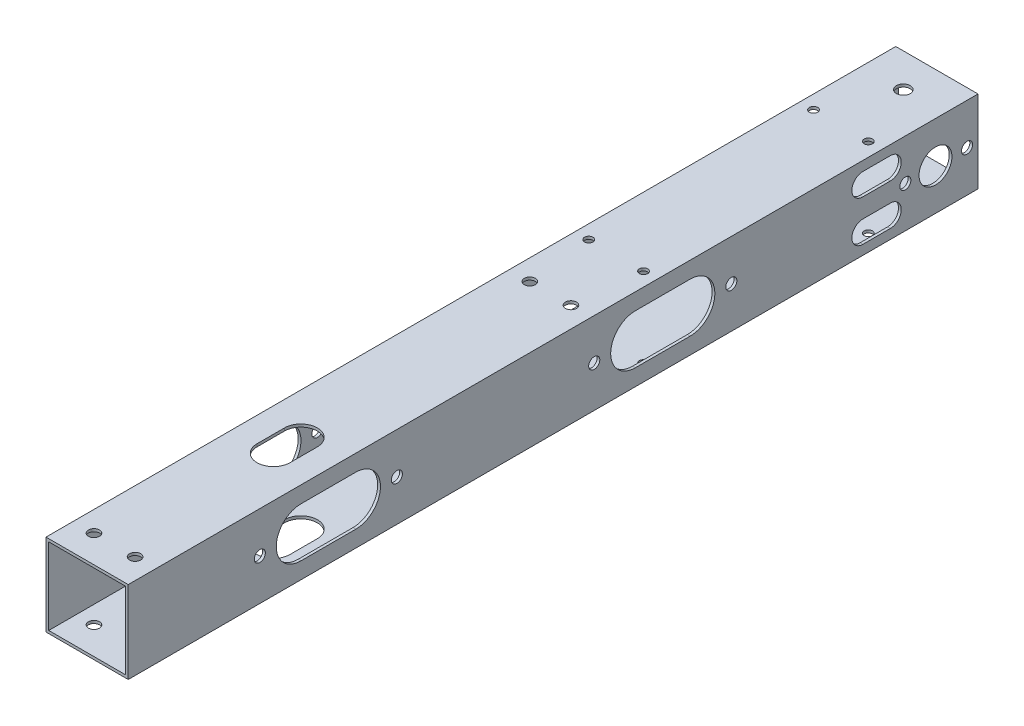
from build123d import *

# Parameters (mm, degrees)
SKETCH_1_W                = 30
SKETCH_1_H                = 30
EXTRUDE_1_DEPTH           = 155
SKETCH_2_W                = 28
SKETCH_2_H                = 28
CUT_EXTRUDE_1_DEPTH       = 156
CUT_EXTRUDE_1_DEPTH_BACK  = 156
SKETCH_3_R                = 2.025
CUT_EXTRUDE_2_DEPTH       = 31
SKETCH_4_R                = 2.025
CUT_EXTRUDE_3_DEPTH       = 1
CUT_EXTRUDE_3_DEPTH_BACK  = 31
SKETCH_5_R                = 2.025
CUT_EXTRUDE_4_DEPTH       = 1
CUT_EXTRUDE_4_DEPTH_BACK  = 31
SKETCH_6_W                = 20
SKETCH_6_H                = 20
CUT_EXTRUDE_5_DEPTH       = 3
FILLET_1_R                = 2
SKETCH_7_R                = 2.025
CUT_EXTRUDE_6_DEPTH       = 1
CUT_EXTRUDE_6_DEPTH_BACK  = 31
SKETCH_8_R                = 6
CUT_EXTRUDE_7_DEPTH       = 1
CUT_EXTRUDE_7_DEPTH_BACK  = 31
SKETCH_9_R                = 1.525
CUT_EXTRUDE_8_DEPTH       = 31
CUT_EXTRUDE_9_DEPTH       = 31
CUT_EXTRUDE_10_DEPTH      = 31
CUT_EXTRUDE_11_DEPTH      = 1
CUT_EXTRUDE_11_DEPTH_BACK = 31
CUT_EXTRUDE_START         = -29
CUT_EXTRUDE_12_DEPTH      = 30
CUT_EXTRUDE_12_DEPTH_BACK = 31
CUT_EXTRUDE_13_REACH      = 32
SKETCH_14_R               = 2.525


with BuildPart() as part:
    # 草图1 → 凸台-拉伸1 (new body, symmetric)
    with BuildSketch(Plane.XY):
        Rectangle(SKETCH_1_W, SKETCH_1_H)
    extrude(amount=EXTRUDE_1_DEPTH, both=True)

    # 草图2 → 切除-拉伸1 (cut, two sides)
    with BuildSketch(Plane.XY) as cut_extrude_1_sk:
        Rectangle(SKETCH_2_W, SKETCH_2_H)
    extrude(amount=CUT_EXTRUDE_1_DEPTH, mode=Mode.SUBTRACT)
    extrude(cut_extrude_1_sk.sketch, amount=-CUT_EXTRUDE_1_DEPTH_BACK, mode=Mode.SUBTRACT)

    # 草图3 → 切除-拉伸2 (cut, through all)
    with BuildSketch(Plane.ZY.offset(15)):
        with Locations((-151, 0)):
            Circle(SKETCH_3_R)
        with Locations((-128.5, 0)):
            Circle(SKETCH_3_R)
    extrude(amount=-CUT_EXTRUDE_2_DEPTH, mode=Mode.SUBTRACT)

    # 草图4 → 切除-拉伸3 (cut, two sides)
    with BuildSketch(Plane.ZY.offset(15)) as cut_extrude_3_sk:
        with Locations((-65, 0)):
            Circle(SKETCH_4_R)
        with Locations((-15, 0)):
            Circle(SKETCH_4_R)
        with Locations((107, 0)):
            Circle(SKETCH_4_R)
        with Locations((57, 0)):
            Circle(SKETCH_4_R)
    extrude(amount=CUT_EXTRUDE_3_DEPTH, mode=Mode.SUBTRACT)
    extrude(cut_extrude_3_sk.sketch, amount=-CUT_EXTRUDE_3_DEPTH_BACK, mode=Mode.SUBTRACT)

    # 草图5 → 切除-拉伸4 (cut, two sides)
    with BuildSketch(Plane.XZ.offset(15)) as cut_extrude_4_sk:
        with Locations((-7.5, 145)):
            Circle(SKETCH_5_R)
        with Locations((7.5, 145)):
            Circle(SKETCH_5_R)
    extrude(amount=CUT_EXTRUDE_4_DEPTH, mode=Mode.SUBTRACT)
    extrude(cut_extrude_4_sk.sketch, amount=-CUT_EXTRUDE_4_DEPTH_BACK, mode=Mode.SUBTRACT)

    # 草图6 → 切除-拉伸5 (cut)
    with BuildSketch(Plane.XZ.offset(15)):
        with Locations((0, -14)):
            Rectangle(SKETCH_6_W, SKETCH_6_H)
    extrude(amount=-CUT_EXTRUDE_5_DEPTH, mode=Mode.SUBTRACT)

    # 圆角1
    fillet_1_edges = [part.edges().sort_by_distance(p)[0] for p in [
        (-10, -14.5, -24),
        (-10, -14.5, -4),
        (10, -14.5, -4),
        (10, -14.5, -24),
    ]]
    fillet(fillet_1_edges, radius=FILLET_1_R)

    # 草图7 → 切除-拉伸6 (cut, two sides)
    with BuildSketch(Plane(origin=(0, 15, 0), x_dir=(1, 0, 0), z_dir=(0, 1, 0))) as cut_extrude_6_sk:
        with Locations((-7.5, 14)):
            Circle(SKETCH_7_R)
        with Locations((7.5, 14)):
            Circle(SKETCH_7_R)
    extrude(amount=CUT_EXTRUDE_6_DEPTH, mode=Mode.SUBTRACT)
    extrude(cut_extrude_6_sk.sketch, amount=-CUT_EXTRUDE_6_DEPTH_BACK, mode=Mode.SUBTRACT)

    # 草图8 → 切除-拉伸7 (cut, two sides)
    with BuildSketch(Plane.ZY.offset(15)) as cut_extrude_7_sk:
        with Locations((-139.5, 0)):
            Circle(SKETCH_8_R)
    extrude(amount=CUT_EXTRUDE_7_DEPTH, mode=Mode.SUBTRACT)
    extrude(cut_extrude_7_sk.sketch, amount=-CUT_EXTRUDE_7_DEPTH_BACK, mode=Mode.SUBTRACT)

    # 草图9 → 切除-拉伸8 (cut, through all)
    with BuildSketch(Plane(origin=(0, 15, 0), x_dir=(1, 0, 0), z_dir=(0, 1, 0))):
        with Locations((-10, 120)):
            Circle(SKETCH_9_R)
        with Locations((10, 120)):
            Circle(SKETCH_9_R)
        with Locations((-10, 38)):
            Circle(SKETCH_9_R)
        with Locations((10, 38)):
            Circle(SKETCH_9_R)
    extrude(amount=-CUT_EXTRUDE_8_DEPTH, mode=Mode.SUBTRACT)

    # 草图10 → 切除-拉伸9 (cut, through all)
    with BuildSketch(Plane.ZY.offset(15)):
        with BuildLine():
            Line((-50, 9), (-30, 9))
            ThreePointArc((-30, 9), (-21, 0), (-30, -9))
            Line((-30, -9), (-50, -9))
            ThreePointArc((-50, -9), (-59, 0), (-50, 9))
        make_face()
    extrude(amount=-CUT_EXTRUDE_9_DEPTH, mode=Mode.SUBTRACT)

    # 草图11 → 切除-拉伸10 (cut, through all)
    with BuildSketch(Plane.ZY.offset(15)):
        with BuildLine():
            Line((-123, 3.5), (-113, 3.5))
            ThreePointArc((-113, 3.5), (-109, 7.5), (-113, 11.5))
            Line((-113, 11.5), (-123, 11.5))
            ThreePointArc((-123, 11.5), (-127, 7.5), (-123, 3.5))
        make_face()
        with BuildLine():
            Line((-123, -11.5), (-113, -11.5))
            ThreePointArc((-113, -11.5), (-109, -7.5), (-113, -3.5))
            Line((-113, -3.5), (-123, -3.5))
            ThreePointArc((-123, -3.5), (-127, -7.5), (-123, -11.5))
        make_face()
    extrude(amount=-CUT_EXTRUDE_10_DEPTH, mode=Mode.SUBTRACT)

    # 草图12 → 切除-拉伸11 (cut, two sides)
    with BuildSketch(Plane.ZY.offset(15)) as cut_extrude_11_sk:
        with BuildLine():
            Line((72, 9), (92, 9))
            ThreePointArc((92, 9), (101, 0), (92, -9))
            Line((92, -9), (72, -9))
            ThreePointArc((72, -9), (63, 0), (72, 9))
        make_face()
    extrude(amount=CUT_EXTRUDE_11_DEPTH, mode=Mode.SUBTRACT)
    extrude(cut_extrude_11_sk.sketch, amount=-CUT_EXTRUDE_11_DEPTH_BACK, mode=Mode.SUBTRACT)

    # 草图13 → 切除-拉伸12 (cut, two sides)
    with BuildSketch(Plane(origin=(0, 15, 0), x_dir=(1, 0, 0), z_dir=(0, 1, 0)).offset(CUT_EXTRUDE_START)) as cut_extrude_12_sk:
        with BuildLine():
            Line((-6, -87), (-6, -77))
            ThreePointArc((-6, -77), (0, -71), (6, -77))
            Line((6, -77), (6, -87))
            ThreePointArc((6, -87), (0, -93), (-6, -87))
        make_face()
    extrude(amount=CUT_EXTRUDE_12_DEPTH, mode=Mode.SUBTRACT)
    extrude(cut_extrude_12_sk.sketch, amount=-CUT_EXTRUDE_12_DEPTH_BACK, mode=Mode.SUBTRACT)

    # 草图14 → 切除-拉伸13 (cut, up to next)
    with BuildSketch(Plane(origin=(0, 15, 0), x_dir=(1, 0, 0), z_dir=(0, 1, 0)), mode=Mode.PRIVATE) as cut_extrude_13_sk1:
        with Locations((0, 142.75)):
            Circle(SKETCH_14_R)
    cut_extrude_13_tool1 = extrude(cut_extrude_13_sk1.sketch, amount=-CUT_EXTRUDE_13_REACH, mode=Mode.PRIVATE) & part.part
    add(cut_extrude_13_tool1.solids().sort_by_distance((0, 15, -142.75))[0], mode=Mode.SUBTRACT)


solid = part.part
